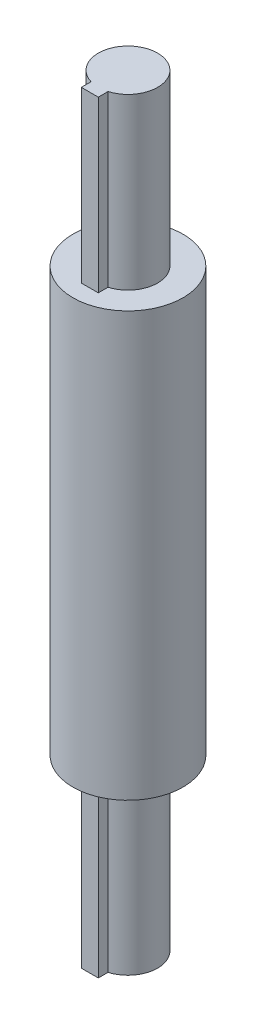
from build123d import *

# Parameters (mm, degrees)
SKETCH1_R                = 3.25
BOSS_EXTRUDE1_DEPTH      = 25
SKETCH2_R                = 1.75
BOSS_EXTRUDE2_DEPTH      = 10
BOSS_EXTRUDE2_DEPTH_BACK = 35
BOSS_EXTRUDE3_START      = -45
SKETCH3_W                = 1
SKETCH3_H                = 1
BOSS_EXTRUDE3_DEPTH      = 45


with BuildPart() as part:
    # Sketch1 → Boss-Extrude1 (new body)
    with BuildSketch(Plane(origin=(0, 0, 0), x_dir=(1, 0, 0), z_dir=(0, 1, 0))):
        Circle(SKETCH1_R)
    extrude(amount=BOSS_EXTRUDE1_DEPTH)

    # Sketch2 → Boss-Extrude2 (add, two sides)
    with BuildSketch(Plane(origin=(0, 25, 0), x_dir=(1, 0, 0), z_dir=(0, 1, 0))) as boss_extrude2_sk:
        Circle(SKETCH2_R)
    extrude(amount=BOSS_EXTRUDE2_DEPTH)
    extrude(boss_extrude2_sk.sketch, amount=-BOSS_EXTRUDE2_DEPTH_BACK)

    # Sketch3 → Boss-Extrude3 (add)
    with BuildSketch(Plane.XZ.offset(10).offset(BOSS_EXTRUDE3_START)):
        with Locations((0, 1.75)):
            Rectangle(SKETCH3_W, SKETCH3_H)
    extrude(amount=BOSS_EXTRUDE3_DEPTH)


solid = part.part
